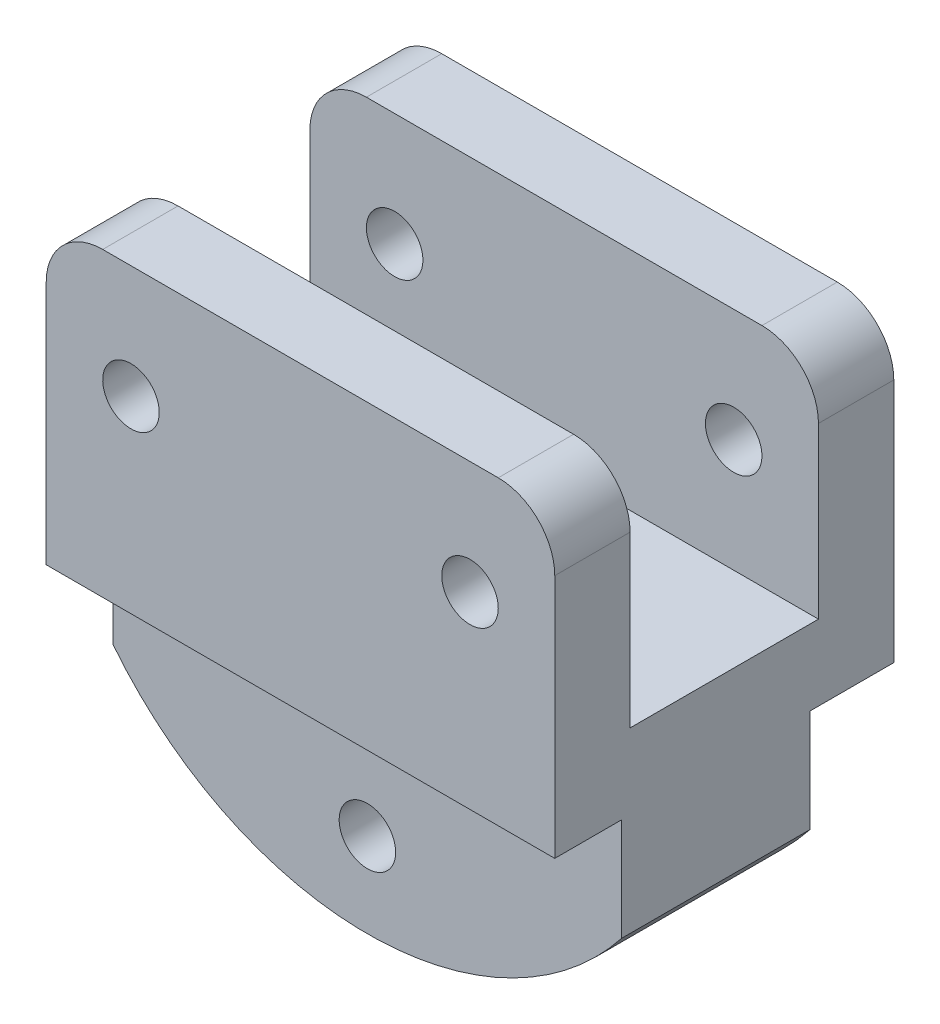
from build123d import *

# Parameters (mm, degrees)
SKETCH2_R           = 1.5
BOSS_EXTRUDE1_DEPTH = 18
SKETCH3_W           = 10
SKETCH3_H           = 12
CUT_EXTRUDE1_DEPTH  = 32
SKETCH4_W           = 27
SKETCH4_H           = 5
BOSS_EXTRUDE3_DEPTH = 12
SKETCH8_R           = 1.5
CUT_EXTRUDE3_DEPTH  = 12
FILLET1_R           = 3
FILLET2_R           = 3
FILLET3_R           = 3
FILLET4_R           = 3


with BuildPart() as part:
    # Sketch2 → Boss-Extrude1 (new body)
    with BuildSketch(Plane.XY):
        Polygon((0, 0), (27, 0), (27, -12), (27, -16), (0, -16), (0, -12), align=None)
        with Locations((4.5, -6)):
            Circle(SKETCH2_R, mode=Mode.SUBTRACT)
        with Locations((22.5, -6)):
            Circle(SKETCH2_R, mode=Mode.SUBTRACT)
    extrude(amount=BOSS_EXTRUDE1_DEPTH)

    # Sketch3 → Cut-Extrude1 (cut)
    with BuildSketch(Plane.ZY):
        with Locations((9, -6)):
            Rectangle(SKETCH3_W, SKETCH3_H)
    extrude(amount=-CUT_EXTRUDE1_DEPTH, mode=Mode.SUBTRACT)

    # Sketch4 → Boss-Extrude3 (add)
    with BuildSketch(Plane.XZ.offset(16)):
        with Locations((13.5, 11.947290181)):
            Rectangle(SKETCH4_W, SKETCH4_H)
        with Locations((13.5, 6.947290181)):
            Rectangle(SKETCH4_W, SKETCH4_H)
    extrude(amount=BOSS_EXTRUDE3_DEPTH)

    # Sketch8 → Cut-Extrude3 (cut)
    with BuildSketch(Plane(origin=(0, 0, 4.447290181), x_dir=(-1, 0, 0), z_dir=(0, 0, -1))):
        with Locations((-13.5, -23.5)):
            Circle(SKETCH8_R)
        with BuildLine():
            Line((-27, -21.451026779), (-27, -28))
            Line((-27, -28), (0, -28))
            Line((0, -28), (0, -21.451026779))
            ThreePointArc((0, -21.451026779), (-13.5, -27.996407915), (-27, -21.451026779))
        make_face()
    extrude(amount=-CUT_EXTRUDE3_DEPTH, mode=Mode.SUBTRACT)

    # Fillet1
    fillet1_edges = [part.edges().sort_by_distance(p)[0] for p in [
        (0, 0, 2),
    ]]
    fillet(fillet1_edges, radius=FILLET1_R)

    # Fillet2
    fillet2_edges = [part.edges().sort_by_distance(p)[0] for p in [
        (27, 0, 2),
    ]]
    fillet(fillet2_edges, radius=FILLET2_R)

    # Fillet3
    fillet3_edges = [part.edges().sort_by_distance(p)[0] for p in [
        (0, 0, 16),
    ]]
    fillet(fillet3_edges, radius=FILLET3_R)

    # Fillet4
    fillet4_edges = [part.edges().sort_by_distance(p)[0] for p in [
        (27, 0, 16),
    ]]
    fillet(fillet4_edges, radius=FILLET4_R)


solid = part.part
